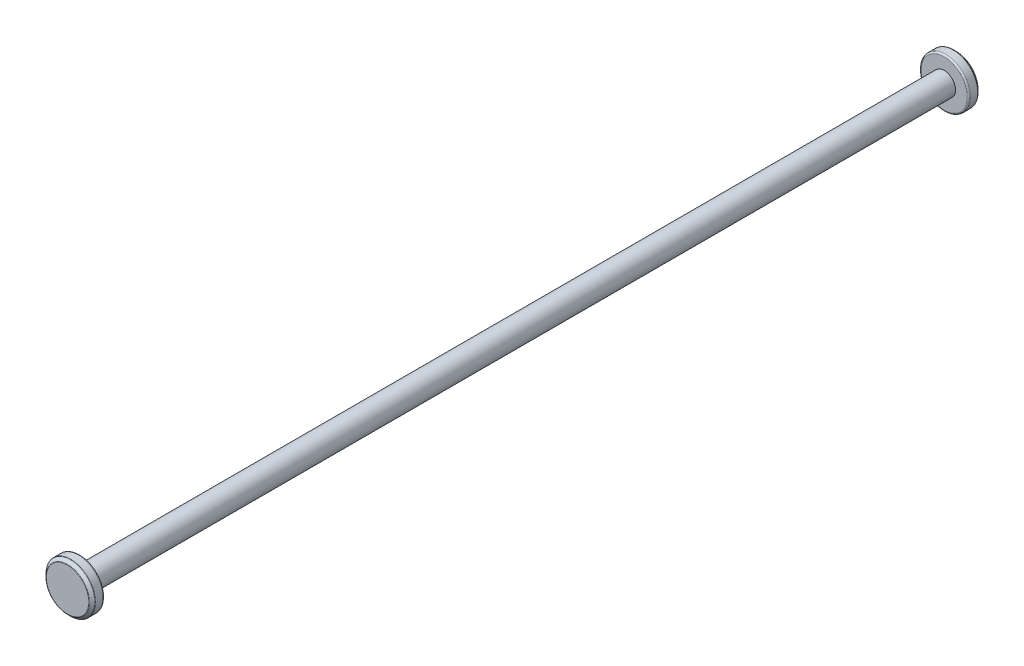
from build123d import *

# Parameters (mm, degrees)
SKETCH1_R                = 1.85
BOSS_EXTRUDE1_DEPTH      = 70.25
SKETCH2_R                = 4
BOSS_EXTRUDE2_DEPTH      = 2
CHAMFER1_SIZE            = 0.5
FILLET2_R                = 0.25
FILLET3_R                = 0.125
CHAMFER1_OF_MIRROR2_SIZE = 0.5
FILLET2_OF_MIRROR2_R     = 0.25
FILLET3_OF_MIRROR2_R     = 0.125


with BuildPart() as part:
    # Sketch1 → Boss-Extrude1 (new body, symmetric)
    with BuildSketch(Plane.XY):
        Circle(SKETCH1_R)
    extrude(amount=BOSS_EXTRUDE1_DEPTH, both=True)

    # Sketch2 → Boss-Extrude2 (add)
    with BuildSketch(Plane(origin=(0, 0, -70.25), x_dir=(-1, 0, 0), z_dir=(0, 0, -1))):
        Circle(SKETCH2_R)
    boss_extrude2 = extrude(amount=BOSS_EXTRUDE2_DEPTH)

    # Chamfer1
    chamfer1_edges = [part.edges().sort_by_distance(p)[0] for p in [
        (4, 0, -72.25),
    ]]
    chamfer(chamfer1_edges, length=CHAMFER1_SIZE)

    # Fillet2
    fillet2_edges = [part.edges().sort_by_distance(p)[0] for p in [
        (4, 0, -70.25),
    ]]
    fillet(fillet2_edges, radius=FILLET2_R)

    # Fillet3
    fillet3_edges = [part.edges().sort_by_distance(p)[0] for p in [
        (4, 0, -71.75),
        (3.5, 0, -72.25),
    ]]
    fillet(fillet3_edges, radius=FILLET3_R)

    # Mirror2: Boss-Extrude2 across plane
    add(boss_extrude2.mirror(Plane.XY))

    # Chamfer1 of Mirror2
    chamfer1_of_mirror2_edges = [part.edges().sort_by_distance(p)[0] for p in [
        (4, 0, 72.25),
    ]]
    chamfer(chamfer1_of_mirror2_edges, length=CHAMFER1_OF_MIRROR2_SIZE)

    # Fillet2 of Mirror2
    fillet2_of_mirror2_edges = [part.edges().sort_by_distance(p)[0] for p in [
        (4, 0, 70.25),
    ]]
    fillet(fillet2_of_mirror2_edges, radius=FILLET2_OF_MIRROR2_R)

    # Fillet3 of Mirror2
    fillet3_of_mirror2_edges = [part.edges().sort_by_distance(p)[0] for p in [
        (4, 0, 71.75),
        (3.5, 0, 72.25),
    ]]
    fillet(fillet3_of_mirror2_edges, radius=FILLET3_OF_MIRROR2_R)


solid = part.part
